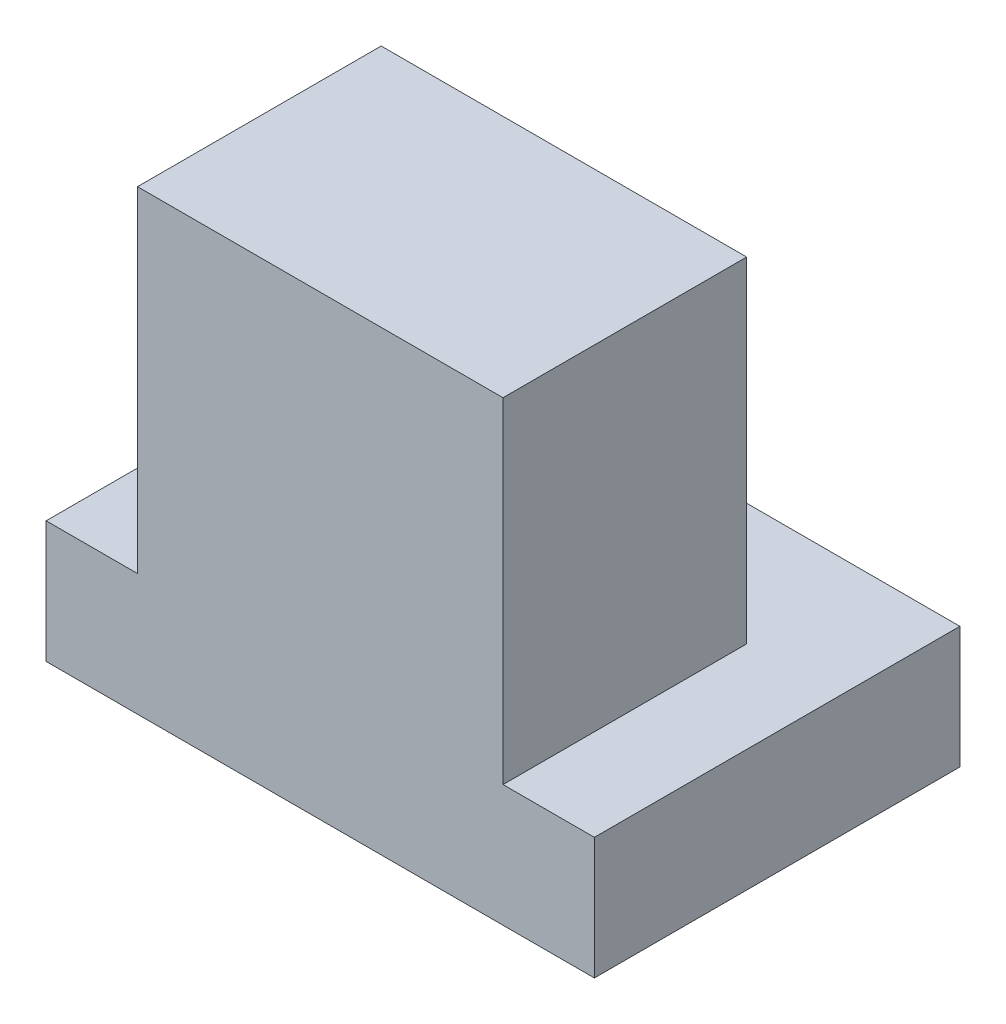
from build123d import *

# Parameters (mm, degrees)
SKETCH1_W           = 6
SKETCH1_H           = 4
BOSS_EXTRUDE1_DEPTH = 7.5
SKETCH2_W           = 1.55
SKETCH2_H           = 4.1
CUT_EXTRUDE1_DEPTH  = 4
SKETCH3_W           = 9
SKETCH3_H           = 6
BOSS_EXTRUDE2_DEPTH = 2


with BuildPart() as part:
    # Sketch1 → Boss-Extrude1 (new body)
    with BuildSketch(Plane(origin=(0, 0, 0), x_dir=(1, 0, 0), z_dir=(0, 1, 0))):
        with Locations((4.5, 2)):
            Rectangle(SKETCH1_W, SKETCH1_H)
    extrude(amount=BOSS_EXTRUDE1_DEPTH)

    # Sketch2 → Cut-Extrude1 (cut)
    with BuildSketch(Plane.ZY.offset(-1.5)):
        with Locations((-2, 4.5)):
            Rectangle(SKETCH2_W, SKETCH2_H)
    extrude(amount=-CUT_EXTRUDE1_DEPTH, mode=Mode.SUBTRACT)

    # Sketch3 → Boss-Extrude2 (add)
    with BuildSketch(Plane(origin=(0, 0, 0), x_dir=(1, 0, 0), z_dir=(0, 1, 0))):
        with Locations((4.5, 3)):
            Rectangle(SKETCH3_W, SKETCH3_H)
    extrude(amount=BOSS_EXTRUDE2_DEPTH)


solid = part.part
